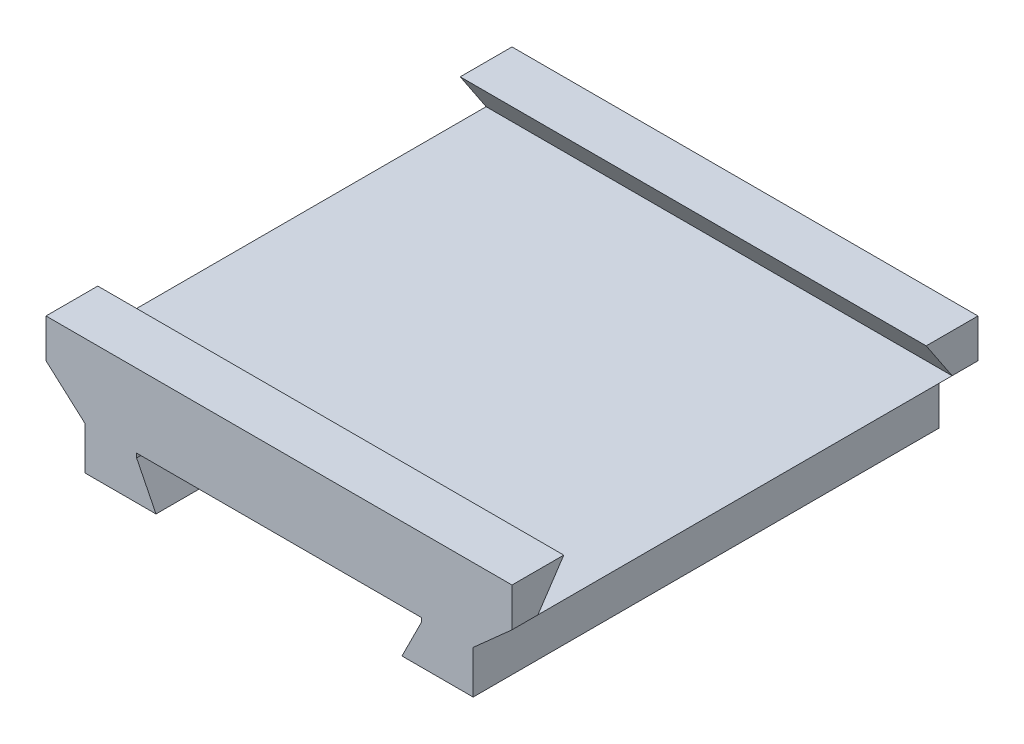
from build123d import *

# Parameters (mm, degrees)
BOSS_EXTRUDE1_DEPTH = 90
CUT_EXTRUDE1_DEPTH  = 180


with BuildPart() as part:
    # Sketch1 → Boss-Extrude1 (new body, symmetric)
    with BuildSketch(Plane.XY):
        Polygon((-55, -61), (-47.5, -76), (-75, -76), (-75, -59.373791994), (-90, -46), (-90, -31), (90, -31), (90, -46), (75, -59.373791994), (75, -76), (47.5, -76), (55, -61), (55, -59.373791994), (-55, -59.373791994), align=None)
    extrude(amount=BOSS_EXTRUDE1_DEPTH, both=True)

    # Sketch2 → Cut-Extrude1 (cut)
    with BuildSketch(Plane(origin=(90, 0, 0), x_dir=(0, 0, -1), z_dir=(1, 0, 0))):
        Polygon((-70, -31), (-80, -46), (80, -46), (70, -31), align=None)
    extrude(amount=-CUT_EXTRUDE1_DEPTH, mode=Mode.SUBTRACT)


solid = part.part
